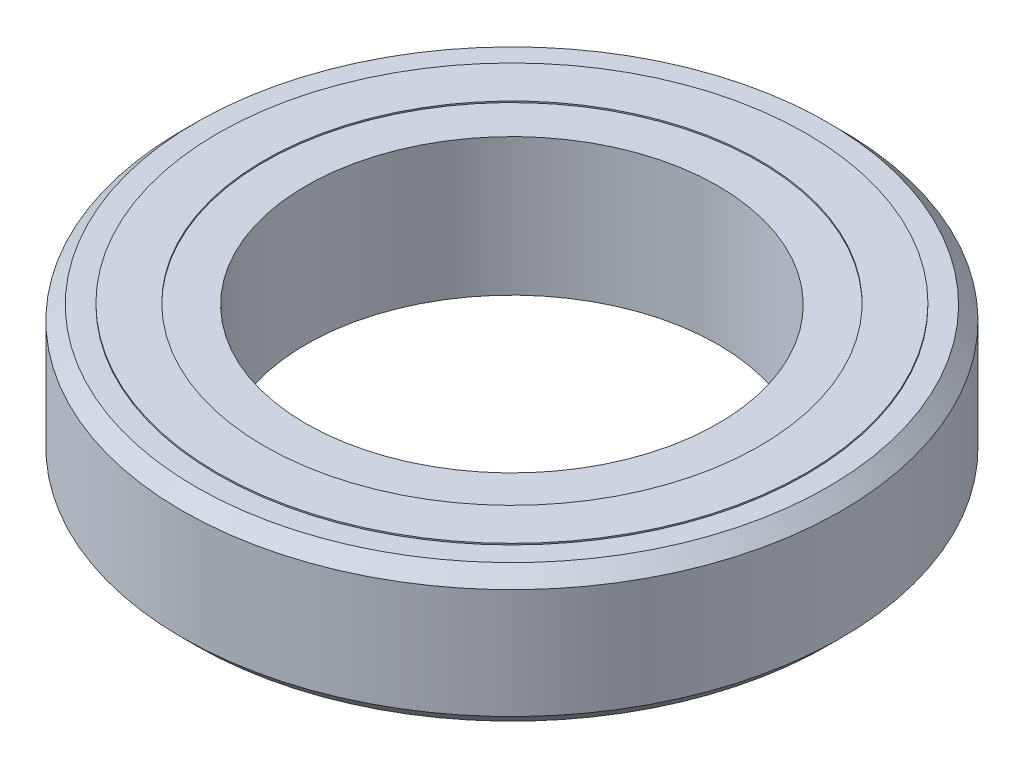
from build123d import *

# Parameters (mm, degrees)
CROQUIS1_R              = 12
CROQUIS1_R_2            = 7.5
SALIENTE_EXTRUIR1_DEPTH = 2.5
CHAFL_N1_SIZE           = 0.5
CROQUIS2_R              = 10.711337482
CROQUIS2_R_2            = 9.016362729
SALIENTE_EXTRUIR2_DEPTH = 2.55


with BuildPart() as part:
    # Croquis1 → Saliente-Extruir1 (new body, symmetric)
    with BuildSketch(Plane(origin=(0, 0, 0), x_dir=(1, 0, 0), z_dir=(0, 1, 0))):
        Circle(CROQUIS1_R)
        Circle(CROQUIS1_R_2, mode=Mode.SUBTRACT)
    extrude(amount=SALIENTE_EXTRUIR1_DEPTH, both=True)

    # Chaflán1
    chafl_n1_edges = [part.edges().sort_by_distance(p)[0] for p in [
        (-12, -2.5, 0),
        (-12, 2.5, 0),
    ]]
    chamfer(chafl_n1_edges, length=CHAFL_N1_SIZE)

    # Croquis2 → Saliente-Extruir2 (add, symmetric)
    with BuildSketch(Plane(origin=(0, 0, 0), x_dir=(1, 0, 0), z_dir=(0, 1, 0))):
        Circle(CROQUIS2_R)
        Circle(CROQUIS2_R_2, mode=Mode.SUBTRACT)
    extrude(amount=SALIENTE_EXTRUIR2_DEPTH, both=True)


solid = part.part
